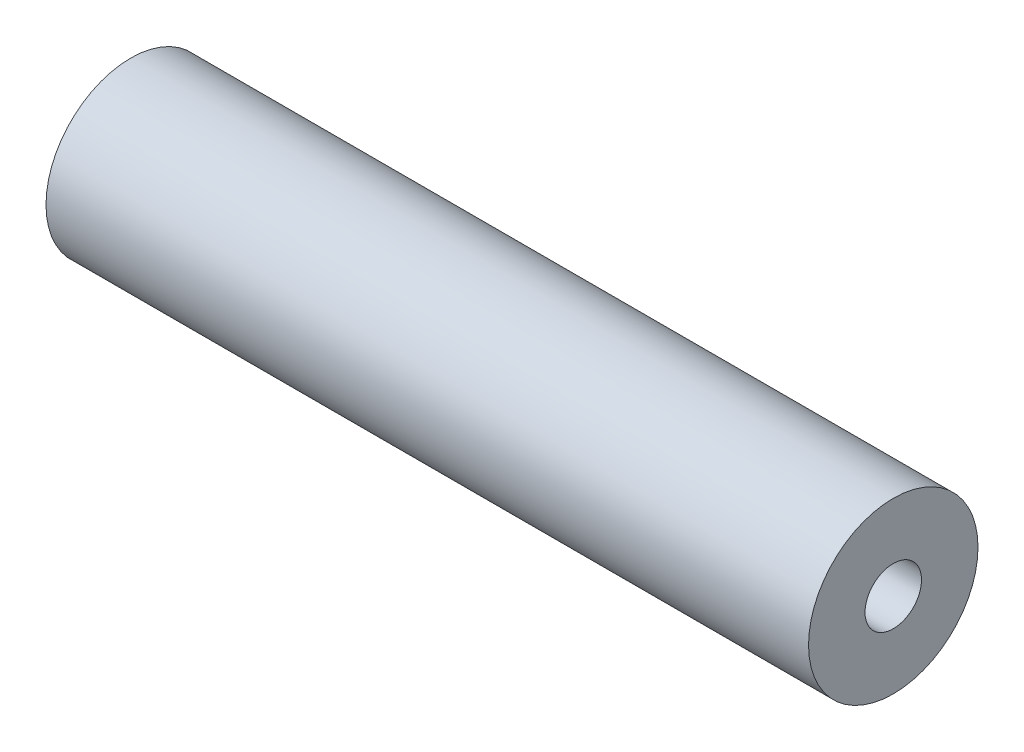
from build123d import *

# Parameters (mm, degrees)
SKETCH_1_R          = 6
EXTRUDE_1_DEPTH     = 54.000054561
SKETCH_2_R          = 2
CUT_EXTRUDE_1_DEPTH = 55.000054561


with BuildPart() as part:
    # Эскиз1 → Бобышка-Вытянуть1 (new body)
    with BuildSketch(Plane(origin=(0, 0, 0), x_dir=(0, 0, -1), z_dir=(1, 0, 0))):
        Circle(SKETCH_1_R)
    extrude(amount=EXTRUDE_1_DEPTH)

    # Эскиз2 → Вырез-Вытянуть1 (cut, through all)
    with BuildSketch(Plane.ZY):
        Circle(SKETCH_2_R)
    extrude(amount=-CUT_EXTRUDE_1_DEPTH, mode=Mode.SUBTRACT)


solid = part.part
